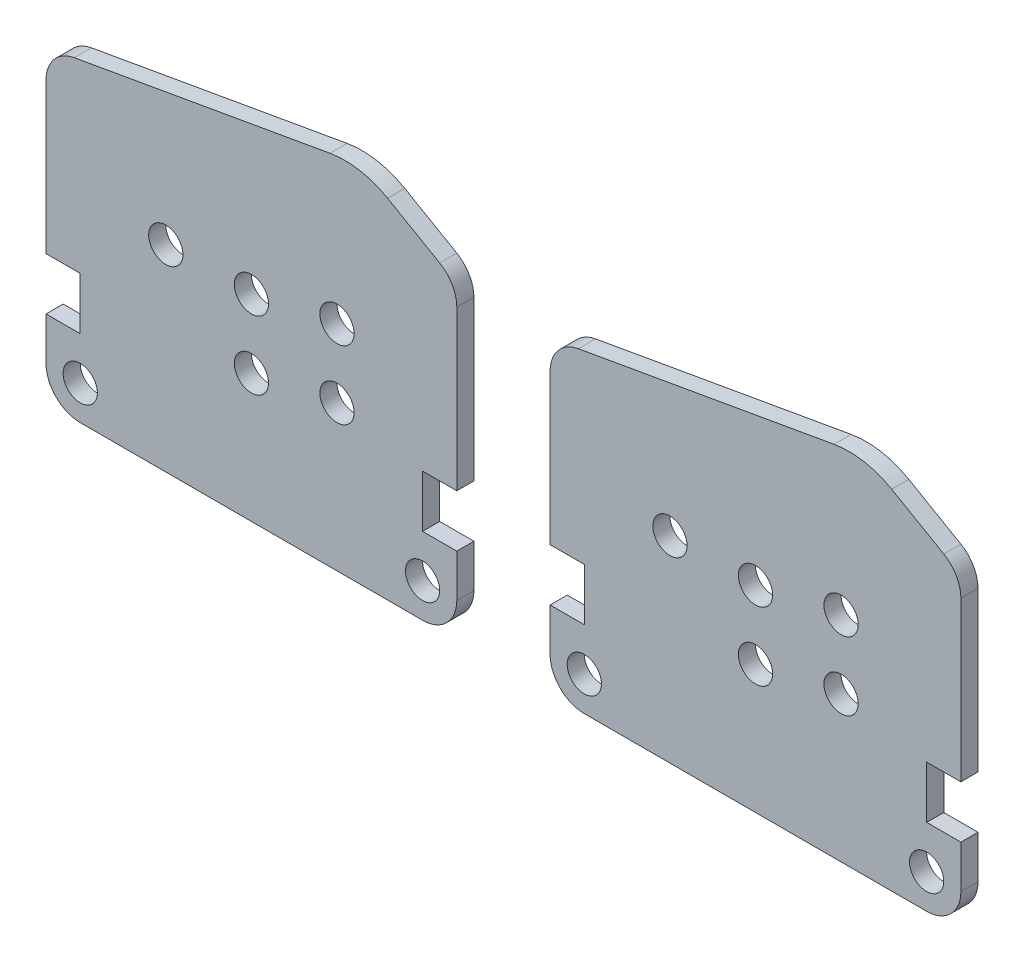
from build123d import *

# Parameters (mm, degrees)
MODEL_R           = 1
EXTRUDE_1_DEPTH   = 1
EXTRUDE_1_2_DEPTH = 1


with BuildPart() as part:
    # Model → 凸台-拉伸1 (new body)
    with BuildSketch(Plane.XY):
        with BuildLine():
            Line((37.863680869, 15.952895964), (37.863680869, 18.452895964))
            Line((37.863680869, 18.452895964), (35.863680869, 18.452895964))
            Line((35.863680869, 18.452895964), (35.863680869, 21.452895994))
            Line((35.863680869, 21.452895994), (35.863680869, 21.502895994))
            Line((35.863680869, 21.502895994), (37.863680869, 21.502895994))
            Line((37.863680869, 21.502895994), (37.863680869, 30.798195426))
            ThreePointArc((37.863680869, 30.798195426), (37.595731677, 31.798195426), (36.863680869, 32.530246234))
            Line((36.863680869, 32.530246234), (33.82478485, 34.284753669))
            ThreePointArc((33.82478485, 34.284753669), (32.193025738, 34.878665415), (30.456543961, 34.878665415))
            Line((30.456543961, 34.878665415), (15.516384514, 32.244312208))
            ThreePointArc((15.516384514, 32.244312208), (14.331591983, 31.560271922), (13.863680869, 30.274696702))
            Line((13.863680869, 30.274696702), (13.863680869, 21.502895994))
            Line((13.863680869, 21.502895994), (15.863680869, 21.502895994))
            Line((15.863680869, 21.502895994), (15.863680869, 21.452895994))
            Line((15.863680869, 21.452895994), (15.863680869, 18.452895964))
            Line((15.863680869, 18.452895964), (13.863680869, 18.452895964))
            Line((13.863680869, 18.452895964), (13.863680869, 15.952895964))
            ThreePointArc((13.863680869, 15.952895964), (14.449467307, 14.538682402), (15.863680869, 13.952895964))
            Line((15.863680869, 13.952895964), (35.863680869, 13.952895964))
            ThreePointArc((35.863680869, 13.952895964), (37.277894432, 14.538682402), (37.863680869, 15.952895964))
        make_face()
        with Locations((35.863680869, 15.952895964)):
            Circle(MODEL_R, mode=Mode.SUBTRACT)
        with Locations((15.863680869, 15.952895964)):
            Circle(MODEL_R, mode=Mode.SUBTRACT)
        with Locations((25.863680869, 25.452895979)):
            Circle(MODEL_R, mode=Mode.SUBTRACT)
        with Locations((20.863680869, 25.452895979)):
            Circle(MODEL_R, mode=Mode.SUBTRACT)
        with Locations((30.863680869, 26.452895979)):
            Circle(MODEL_R, mode=Mode.SUBTRACT)
        with Locations((25.863680869, 21.452895979)):
            Circle(MODEL_R, mode=Mode.SUBTRACT)
        with Locations((30.863680869, 22.452895979)):
            Circle(MODEL_R, mode=Mode.SUBTRACT)
    extrude(amount=EXTRUDE_1_DEPTH)


with BuildPart() as body_2:
    # Model → Extrude 1 2 (new body)
    with BuildSketch(Plane.XY):
        with BuildLine():
            Line((67.314390859, 15.952895964), (67.314390859, 18.452895964))
            Line((67.314390859, 18.452895964), (65.314390859, 18.452895964))
            Line((65.314390859, 18.452895964), (65.314390859, 21.452895994))
            Line((65.314390859, 21.452895994), (65.314390859, 21.502895994))
            Line((65.314390859, 21.502895994), (67.314390859, 21.502895994))
            Line((67.314390859, 21.502895994), (67.314390859, 30.798195426))
            ThreePointArc((67.314390859, 30.798195426), (67.046441666, 31.798195426), (66.314390859, 32.530246234))
            Line((66.314390859, 32.530246234), (63.275494839, 34.284753669))
            ThreePointArc((63.275494839, 34.284753669), (61.643735727, 34.878665415), (59.907253951, 34.878665415))
            Line((59.907253951, 34.878665415), (44.967094503, 32.244312208))
            ThreePointArc((44.967094503, 32.244312208), (43.782301973, 31.560271922), (43.314390859, 30.274696702))
            Line((43.314390859, 30.274696702), (43.314390859, 21.502895994))
            Line((43.314390859, 21.502895994), (45.314390859, 21.502895994))
            Line((45.314390859, 21.502895994), (45.314390859, 21.452895994))
            Line((45.314390859, 21.452895994), (45.314390859, 18.452895964))
            Line((45.314390859, 18.452895964), (43.314390859, 18.452895964))
            Line((43.314390859, 18.452895964), (43.314390859, 15.952895964))
            ThreePointArc((43.314390859, 15.952895964), (43.900177296, 14.538682402), (45.314390859, 13.952895964))
            Line((45.314390859, 13.952895964), (65.314390859, 13.952895964))
            ThreePointArc((65.314390859, 13.952895964), (66.728604421, 14.538682402), (67.314390859, 15.952895964))
        make_face()
        with Locations((65.314390859, 15.952895964)):
            Circle(MODEL_R, mode=Mode.SUBTRACT)
        with Locations((45.314390859, 15.952895964)):
            Circle(MODEL_R, mode=Mode.SUBTRACT)
        with Locations((55.314390859, 25.452895979)):
            Circle(MODEL_R, mode=Mode.SUBTRACT)
        with Locations((50.314390859, 25.452895979)):
            Circle(MODEL_R, mode=Mode.SUBTRACT)
        with Locations((60.314390859, 26.452895979)):
            Circle(MODEL_R, mode=Mode.SUBTRACT)
        with Locations((55.314390859, 21.452895979)):
            Circle(MODEL_R, mode=Mode.SUBTRACT)
        with Locations((60.314390859, 22.452895979)):
            Circle(MODEL_R, mode=Mode.SUBTRACT)
    extrude(amount=EXTRUDE_1_2_DEPTH)


solid = Compound([part.part, body_2.part])
